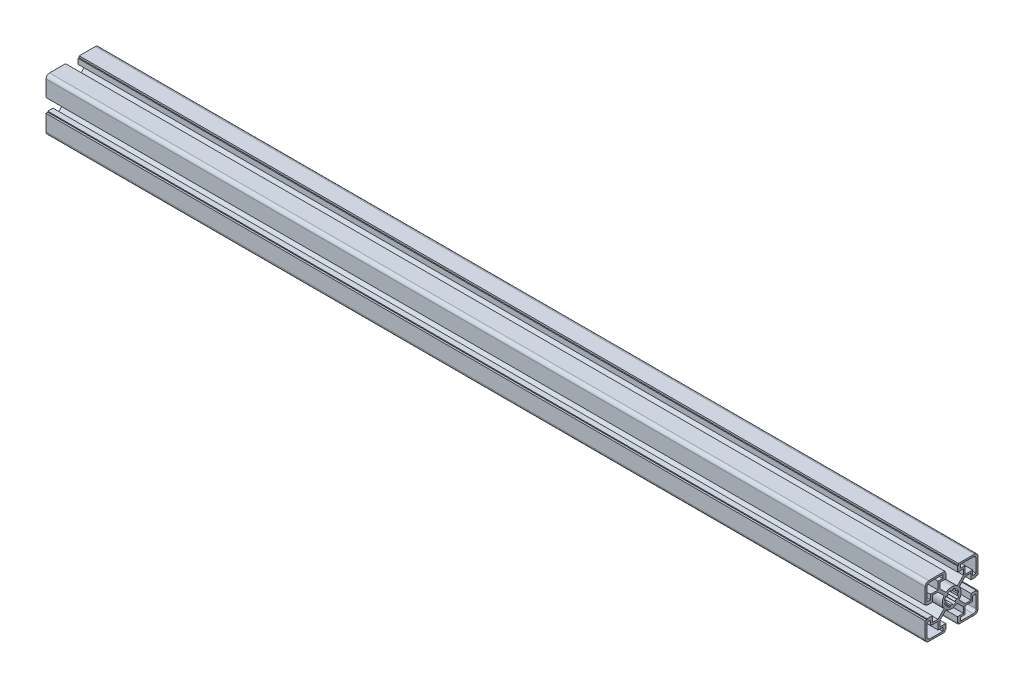
from build123d import *

# Parameters (mm, degrees)
BR_EXTRUDE_DEPTH      = 397.5
BR_EXTRUDE_DEPTH_BACK = 352.5


with BuildPart() as part:
    # Sketch2 → BR_Extrude (new body, two sides)
    with BuildSketch(Plane(origin=(0, 0, 0), x_dir=(0, 0, -1), z_dir=(1, 0, 0))) as br_extrude_sk:
        with BuildLine():
            Line((-10.05, 11.676345597), (-10.05, 16.5))
            Line((-10.05, 16.5), (-5, 16.5))
            Line((-5, 16.5), (-5, 21))
            Line((-5, 21), (-5.8, 21))
            Line((-5.8, 21), (-5.8, 22.5))
            Line((-5.8, 22.5), (-19.5, 22.5))
            ThreePointArc((-19.5, 22.5), (-21.621320344, 21.621320344), (-22.5, 19.5))
            Line((-22.5, 19.5), (-22.5, 5.8))
            Line((-22.5, 5.8), (-21, 5.8))
            Line((-21, 5.8), (-21, 5))
            Line((-21, 5), (-16.5, 5))
            Line((-16.5, 5), (-16.5, 10.05))
            Line((-16.5, 10.05), (-11.676345597, 10.05))
            Line((-11.676345597, 10.05), (-6.411275155, 4.784929559))
            ThreePointArc((-6.411275155, 4.784929559), (-8, 0), (-6.411275155, -4.784929559))
            Line((-6.411275155, -4.784929559), (-11.676345597, -10.05))
            Line((-11.676345597, -10.05), (-16.5, -10.05))
            Line((-16.5, -10.05), (-16.5, -5))
            Line((-16.5, -5), (-21, -5))
            Line((-21, -5), (-21, -5.8))
            Line((-21, -5.8), (-22.5, -5.8))
            Line((-22.5, -5.8), (-22.5, -19.5))
            ThreePointArc((-22.5, -19.5), (-21.621320344, -21.621320344), (-19.5, -22.5))
            Line((-19.5, -22.5), (-5.8, -22.5))
            Line((-5.8, -22.5), (-5.8, -21))
            Line((-5.8, -21), (-5, -21))
            Line((-5, -21), (-5, -16.5))
            Line((-5, -16.5), (-10.05, -16.5))
            Line((-10.05, -16.5), (-10.05, -11.676345597))
            Line((-10.05, -11.676345597), (-4.784929559, -6.411275155))
            ThreePointArc((-4.784929559, -6.411275155), (0, -8), (4.784929559, -6.411275155))
            Line((4.784929559, -6.411275155), (10.05, -11.676345597))
            Line((10.05, -11.676345597), (10.05, -16.5))
            Line((10.05, -16.5), (5, -16.5))
            Line((5, -16.5), (5, -21))
            Line((5, -21), (5.8, -21))
            Line((5.8, -21), (5.8, -22.5))
            Line((5.8, -22.5), (19.5, -22.5))
            ThreePointArc((19.5, -22.5), (21.621320344, -21.621320344), (22.5, -19.5))
            Line((22.5, -19.5), (22.5, -5.8))
            Line((22.5, -5.8), (21, -5.8))
            Line((21, -5.8), (21, -5))
            Line((21, -5), (16.5, -5))
            Line((16.5, -5), (16.5, -10.05))
            Line((16.5, -10.05), (11.676345597, -10.05))
            Line((11.676345597, -10.05), (6.411275155, -4.784929559))
            ThreePointArc((6.411275155, -4.784929559), (8, 0), (6.411275155, 4.784929559))
            Line((6.411275155, 4.784929559), (11.676345597, 10.05))
            Line((11.676345597, 10.05), (16.5, 10.05))
            Line((16.5, 10.05), (16.5, 5))
            Line((16.5, 5), (21, 5))
            Line((21, 5), (21, 5.8))
            Line((21, 5.8), (22.5, 5.8))
            Line((22.5, 5.8), (22.5, 19.5))
            ThreePointArc((22.5, 19.5), (21.621320344, 21.621320344), (19.5, 22.5))
            Line((19.5, 22.5), (5.8, 22.5))
            Line((5.8, 22.5), (5.8, 21))
            Line((5.8, 21), (5, 21))
            Line((5, 21), (5, 16.5))
            Line((5, 16.5), (10.05, 16.5))
            Line((10.05, 16.5), (10.05, 11.676345597))
            Line((10.05, 11.676345597), (4.784929559, 6.411275155))
            ThreePointArc((4.784929559, 6.411275155), (0, 8), (-4.784929559, 6.411275155))
            Line((-4.784929559, 6.411275155), (-10.05, 11.676345597))
        make_face()
        with BuildLine():
            Line((11.55, 11.55), (11.55, 18))
            Line((11.55, 18), (7.5, 18))
            Line((7.5, 18), (7.5, 21))
            Line((7.5, 21), (18.5, 21))
            ThreePointArc((18.5, 21), (20.267766953, 20.267766953), (21, 18.5))
            Line((21, 18.5), (21, 7.5))
            Line((21, 7.5), (18, 7.5))
            Line((18, 7.5), (18, 11.55))
            Line((18, 11.55), (11.55, 11.55))
        make_face(mode=Mode.SUBTRACT)
        with BuildLine():
            Line((11.55, -11.55), (18, -11.55))
            Line((18, -11.55), (18, -7.5))
            Line((18, -7.5), (21, -7.5))
            Line((21, -7.5), (21, -18.5))
            ThreePointArc((21, -18.5), (20.267766953, -20.267766953), (18.5, -21))
            Line((18.5, -21), (7.5, -21))
            Line((7.5, -21), (7.5, -18))
            Line((7.5, -18), (11.55, -18))
            Line((11.55, -18), (11.55, -11.55))
        make_face(mode=Mode.SUBTRACT)
        with BuildLine():
            Line((-11.55, 11.55), (-18, 11.55))
            Line((-18, 11.55), (-18, 7.5))
            Line((-18, 7.5), (-21, 7.5))
            Line((-21, 7.5), (-21, 18.5))
            ThreePointArc((-21, 18.5), (-20.267766953, 20.267766953), (-18.5, 21))
            Line((-18.5, 21), (-7.5, 21))
            Line((-7.5, 21), (-7.5, 18))
            Line((-7.5, 18), (-11.55, 18))
            Line((-11.55, 18), (-11.55, 11.55))
        make_face(mode=Mode.SUBTRACT)
        with BuildLine():
            Line((-11.55, -11.55), (-11.55, -18))
            Line((-11.55, -18), (-7.5, -18))
            Line((-7.5, -18), (-7.5, -21))
            Line((-7.5, -21), (-18.5, -21))
            ThreePointArc((-18.5, -21), (-20.267766953, -20.267766953), (-21, -18.5))
            Line((-21, -18.5), (-21, -7.5))
            Line((-21, -7.5), (-18, -7.5))
            Line((-18, -7.5), (-18, -11.55))
            Line((-18, -11.55), (-11.55, -11.55))
        make_face(mode=Mode.SUBTRACT)
        with BuildLine():
            Line((-6.007327293, -1.059253884), (-4.924038765, -0.868240888))
            ThreePointArc((-4.924038765, -0.868240888), (-5, 0), (-4.924038765, 0.868240888))
            Line((-4.924038765, 0.868240888), (-6.007327293, 1.059253884))
            ThreePointArc((-6.007327293, 1.059253884), (-5.635665148, 2.334368937), (-4.99682747, 3.498816262))
            Line((-4.99682747, 3.498816262), (-4.095760221, 2.867882182))
            ThreePointArc((-4.095760221, 2.867882182), (-3.535533906, 3.535533906), (-2.867882182, 4.095760221))
            Line((-2.867882182, 4.095760221), (-3.498816262, 4.99682747))
            ThreePointArc((-3.498816262, 4.99682747), (-2.334368937, 5.635665148), (-1.059253884, 6.007327293))
            Line((-1.059253884, 6.007327293), (-0.868240888, 4.924038765))
            ThreePointArc((-0.868240888, 4.924038765), (0, 5), (0.868240888, 4.924038765))
            Line((0.868240888, 4.924038765), (1.059253884, 6.007327293))
            ThreePointArc((1.059253884, 6.007327293), (2.334368937, 5.635665148), (3.498816262, 4.99682747))
            Line((3.498816262, 4.99682747), (2.867882182, 4.095760221))
            ThreePointArc((2.867882182, 4.095760221), (3.535533906, 3.535533906), (4.095760221, 2.867882182))
            Line((4.095760221, 2.867882182), (4.99682747, 3.498816262))
            ThreePointArc((4.99682747, 3.498816262), (5.635665148, 2.334368937), (6.007327293, 1.059253884))
            Line((6.007327293, 1.059253884), (4.924038765, 0.868240888))
            ThreePointArc((4.924038765, 0.868240888), (5, 0), (4.924038765, -0.868240888))
            Line((4.924038765, -0.868240888), (6.007327293, -1.059253884))
            ThreePointArc((6.007327293, -1.059253884), (5.635665148, -2.334368937), (4.99682747, -3.498816262))
            Line((4.99682747, -3.498816262), (4.095760221, -2.867882182))
            ThreePointArc((4.095760221, -2.867882182), (3.535533906, -3.535533906), (2.867882182, -4.095760221))
            Line((2.867882182, -4.095760221), (3.498816262, -4.99682747))
            ThreePointArc((3.498816262, -4.99682747), (2.334368937, -5.635665148), (1.059253884, -6.007327293))
            Line((1.059253884, -6.007327293), (0.868240888, -4.924038765))
            ThreePointArc((0.868240888, -4.924038765), (0, -5), (-0.868240888, -4.924038765))
            Line((-0.868240888, -4.924038765), (-1.059253884, -6.007327293))
            ThreePointArc((-1.059253884, -6.007327293), (-2.334368937, -5.635665148), (-3.498816262, -4.99682747))
            Line((-3.498816262, -4.99682747), (-2.867882182, -4.095760221))
            ThreePointArc((-2.867882182, -4.095760221), (-3.535533906, -3.535533906), (-4.095760221, -2.867882182))
            Line((-4.095760221, -2.867882182), (-4.99682747, -3.498816262))
            ThreePointArc((-4.99682747, -3.498816262), (-5.635665148, -2.334368937), (-6.007327293, -1.059253884))
        make_face(mode=Mode.SUBTRACT)
    extrude(amount=BR_EXTRUDE_DEPTH)
    extrude(br_extrude_sk.sketch, amount=-BR_EXTRUDE_DEPTH_BACK)


solid = part.part
